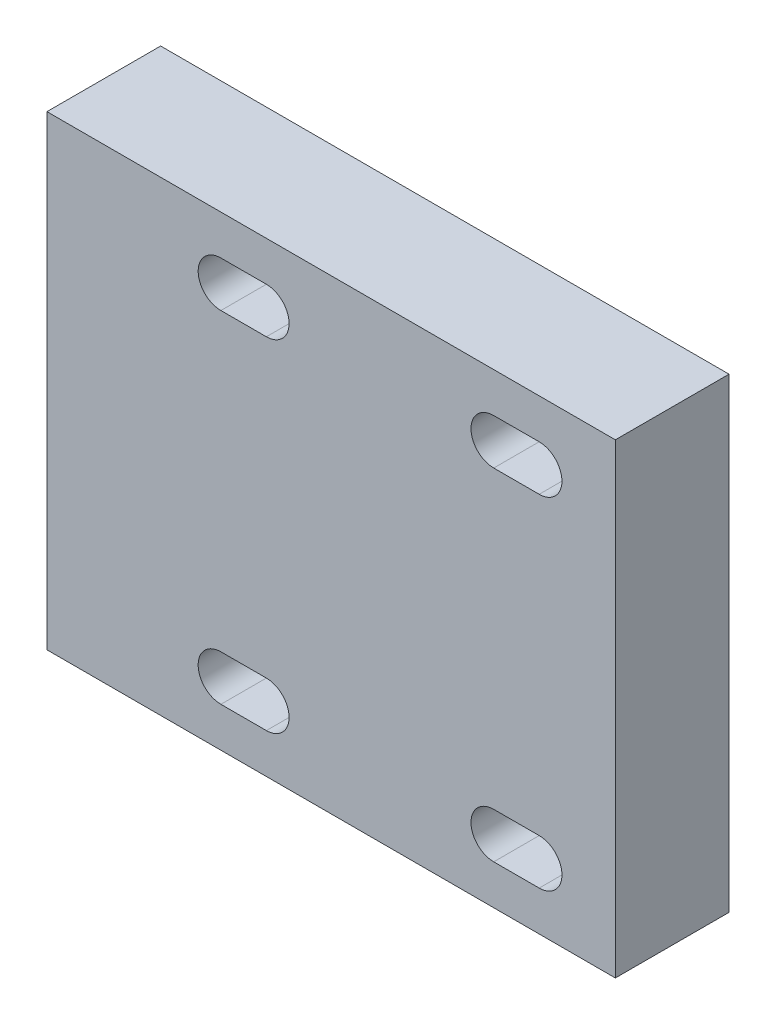
from build123d import *

# Parameters (mm, degrees)
SKETCH1_W           = 50
SKETCH1_H           = 41
BOSS_EXTRUDE1_DEPTH = 10
CUT_EXTRUDE1_DEPTH  = 10


with BuildPart() as part:
    # Sketch1 → Boss-Extrude1 (new body)
    with BuildSketch(Plane.XY):
        Rectangle(SKETCH1_W, SKETCH1_H)
    extrude(amount=BOSS_EXTRUDE1_DEPTH)

    # Sketch2 → Cut-Extrude1 (cut)
    with BuildSketch(Plane(origin=(0, 0, 0), x_dir=(-1, 0, 0), z_dir=(0, 0, -1))):
        with BuildLine():
            Line((9.7, -17), (5.7, -17))
            ThreePointArc((5.7, -17), (3.7, -15), (5.7, -13))
            Line((5.7, -13), (9.7, -13))
            ThreePointArc((9.7, -13), (11.7, -15), (9.7, -17))
        make_face()
        with BuildLine():
            Line((-14.3, -17), (-18.3, -17))
            ThreePointArc((-18.3, -17), (-20.3, -15), (-18.3, -13))
            Line((-18.3, -13), (-14.3, -13))
            ThreePointArc((-14.3, -13), (-12.3, -15), (-14.3, -17))
        make_face()
        with BuildLine():
            Line((5.7, 13), (9.7, 13))
            ThreePointArc((9.7, 13), (11.7, 15), (9.7, 17))
            Line((9.7, 17), (5.7, 17))
            ThreePointArc((5.7, 17), (3.7, 15), (5.7, 13))
        make_face()
        with BuildLine():
            Line((-18.3, 13), (-14.3, 13))
            ThreePointArc((-14.3, 13), (-12.3, 15), (-14.3, 17))
            Line((-14.3, 17), (-18.3, 17))
            ThreePointArc((-18.3, 17), (-20.3, 15), (-18.3, 13))
        make_face()
    extrude(amount=-CUT_EXTRUDE1_DEPTH, mode=Mode.SUBTRACT)


solid = part.part
